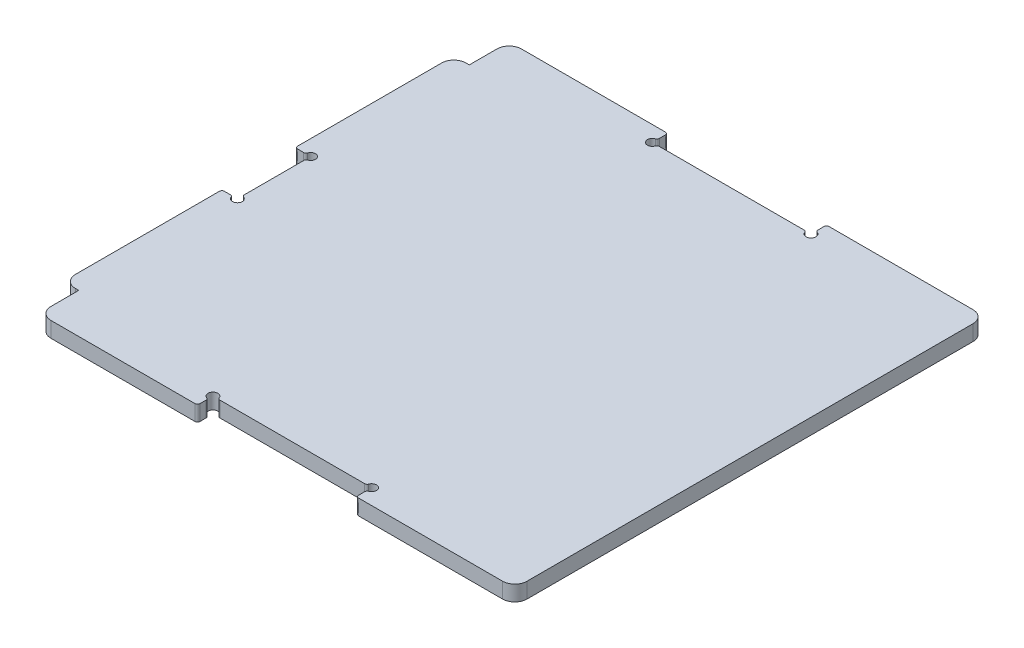
from build123d import *

# Parameters (mm, degrees)
SKETCH1_W               = 195
SKETCH1_H               = 180
BOSS_EXTRUDE1_DEPTH     = 3.175
SKETCH2_W               = 65
SKETCH2_H               = 6.35
BOSS_EXTRUDE2_DEPTH     = 6.35
LPATTERN1_COUNT         = 2
LPATTERN1_PITCH         = 130
MIRROR1_COPY_1_SKETCH_W = 65
MIRROR1_COPY_1_SKETCH_H = 6.35
MIRROR1_COPY_1_DEPTH    = 6.35
SKETCH3_W               = 6.35
SKETCH3_H               = 65
BOSS_EXTRUDE3_DEPTH     = 6.35
SKETCH4_R               = 2
CUT_EXTRUDE1_DEPTH      = 7.35
FILLET1_R               = 1
CUT_EXTRUDE2_DEPTH      = 7.35
SKETCH6_R               = 2
CUT_EXTRUDE3_DEPTH      = 7.35
FILLET2_R               = 1
FILLET3_R               = 5


with BuildPart() as part:
    # Sketch1 → Boss-Extrude1 (new body, symmetric)
    with BuildSketch(Plane(origin=(0, 0, 0), x_dir=(1, 0, 0), z_dir=(0, 1, 0))):
        with Locations((97.5, 90)):
            Rectangle(SKETCH1_W, SKETCH1_H)
    extrude(amount=BOSS_EXTRUDE1_DEPTH, both=True)

    # Sketch2 → Boss-Extrude2 (add)
    with BuildSketch(Plane(origin=(0, 3.175, 0), x_dir=(1, 0, 0), z_dir=(0, 1, 0))):
        with Locations((162.5, -3.175)):
            Rectangle(SKETCH2_W, SKETCH2_H)
    boss_extrude2 = extrude(amount=-BOSS_EXTRUDE2_DEPTH)

    # LPattern1: Boss-Extrude2 ×2
    with Locations(*[(-i * LPATTERN1_PITCH, 0, 0) for i in range(1, LPATTERN1_COUNT)]):
        add(boss_extrude2)

    # Mirror1: Boss-Extrude2 across plane
    add(boss_extrude2.mirror(Plane.XY.offset(-90)))

    # Mirror1 copy 1 sketch → Mirror1 copy 1 (add)
    with BuildSketch(Plane(origin=(-130, 3.175, -180), x_dir=(1, 0, 0), z_dir=(0, 1, 0))):
        with Locations((162.5, 3.175)):
            Rectangle(MIRROR1_COPY_1_SKETCH_W, MIRROR1_COPY_1_SKETCH_H)
    extrude(amount=-MIRROR1_COPY_1_DEPTH)

    # Sketch3 → Boss-Extrude3 (add)
    with BuildSketch(Plane(origin=(0, 3.175, 0), x_dir=(1, 0, 0), z_dir=(0, 1, 0))):
        with Locations((-3.175, 137.5)):
            Rectangle(SKETCH3_W, SKETCH3_H)
        with Locations((-3.175, 42.5)):
            Rectangle(SKETCH3_W, SKETCH3_H)
    extrude(amount=-BOSS_EXTRUDE3_DEPTH)

    # Sketch4 → Cut-Extrude1 (cut, through all)
    with BuildSketch(Plane(origin=(0, 3.175, 0), x_dir=(1, 0, 0), z_dir=(0, 1, 0))):
        with Locations((65, 0)):
            Circle(SKETCH4_R)
        with Locations((130, 0)):
            Circle(SKETCH4_R)
    extrude(amount=-CUT_EXTRUDE1_DEPTH, mode=Mode.SUBTRACT)

    # Fillet1
    fillet1_edges = [part.edges().sort_by_distance(p)[0] for p in [
        (130, 0, 6.35),
        (65, 0, 6.35),
    ]]
    fillet(fillet1_edges, radius=FILLET1_R)

    # Sketch5 → Cut-Extrude2 (cut, through all)
    with BuildSketch(Plane(origin=(0, 3.175, 0), x_dir=(1, 0, 0), z_dir=(0, 1, 0))):
        with BuildLine():
            Line((130, -2.828427125), (130, -5.35))
            ThreePointArc((130, -5.35), (130.292893219, -6.057106781), (131, -6.35))
            Line((131, -6.35), (64, -6.35))
            ThreePointArc((64, -6.35), (64.707106781, -6.057106781), (65, -5.35))
            Line((65, -5.35), (65, -2.828427125))
            ThreePointArc((65, -2.828427125), (64.816496581, -2.251076856), (64.333333333, -1.885618083))
            ThreePointArc((64.333333333, -1.885618083), (63.585786438, 1.414213562), (66.885618083, 0.666666667))
            ThreePointArc((66.885618083, 0.666666667), (67.251076856, 0.183503419), (67.828427125, 0))
            Line((67.828427125, 0), (127.171572875, 0))
            ThreePointArc((127.171572875, 0), (127.748923144, 0.183503419), (128.114381917, 0.666666667))
            ThreePointArc((128.114381917, 0.666666667), (131.414213562, 1.414213562), (130.666666667, -1.885618083))
            ThreePointArc((130.666666667, -1.885618083), (130.183503419, -2.251076856), (130, -2.828427125))
        make_face()
    cut_extrude2 = extrude(amount=-CUT_EXTRUDE2_DEPTH, mode=Mode.SUBTRACT)

    # Mirror3: Cut-Extrude2 across plane
    add(cut_extrude2.mirror(Plane.XY.offset(-90)), mode=Mode.SUBTRACT)

    # Sketch6 → Cut-Extrude3 (cut, through all)
    with BuildSketch(Plane(origin=(0, 3.175, 0), x_dir=(1, 0, 0), z_dir=(0, 1, 0))):
        with Locations((0, 105)):
            Circle(SKETCH6_R)
        with Locations((0, 75)):
            Circle(SKETCH6_R)
    extrude(amount=-CUT_EXTRUDE3_DEPTH, mode=Mode.SUBTRACT)

    # Fillet2
    fillet2_edges = [part.edges().sort_by_distance(p)[0] for p in [
        (-2, 0, -75),
        (-2, 0, -105),
        (0, 0, -103),
        (0, 0, -77),
        (-6.35, 0, -105),
        (-6.35, 0, -75),
    ]]
    fillet(fillet2_edges, radius=FILLET2_R)

    # Fillet3
    fillet3_edges = [part.edges().sort_by_distance(p)[0] for p in [
        (195, 0, 6.35),
        (0, 0, 6.35),
        (195, 0, -186.35),
        (0, 0, -186.35),
        (-6.35, 0, -170),
        (-6.35, 0, -10),
    ]]
    fillet(fillet3_edges, radius=FILLET3_R)


solid = part.part
